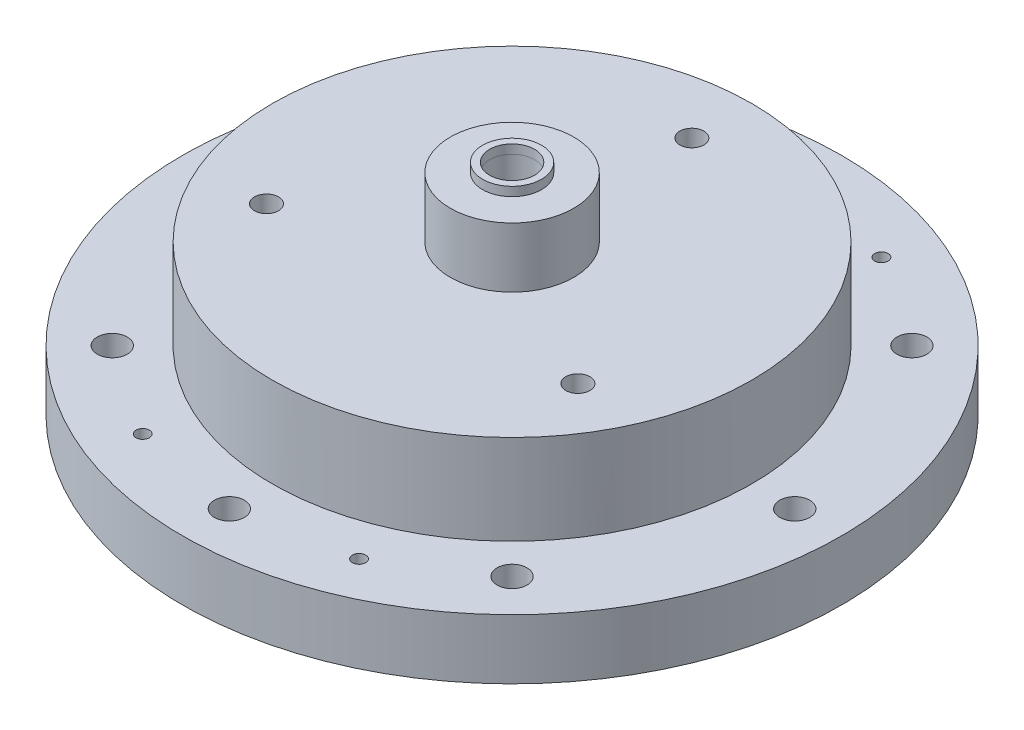
from build123d import *

# Parameters (mm, degrees)
SKETCH1_R                        = 50.8
BOSS_EXTRUDE1_DEPTH              = 25.4
SKETCH2_R                        = 69.85
SKETCH2_R_2                      = 50.8
BOSS_EXTRUDE2_DEPTH              = 12.7
CUT_EXTRUDE2_REACH               = 27.4
SKETCH4_R                        = 3.175
SKETCH5_R                        = 12.827
CUT_EXTRUDE3_DEPTH               = 19.05
CUT_EXTRUDE4_REACH               = 8.35
SKETCH6_R                        = 1.5875
SKETCH34_R                       = 13.081
SKETCH34_R_2                     = 4.7625
BOSS_EXTRUDE3_DEPTH              = 19.05
SKETCH40_R                       = 50.8
BOSS_EXTRUDE5_DEPTH              = 6.35
SKETCH38_R                       = 6.2484
BOSS_EXTRUDE4_DEPTH              = 1.905
SKETCH39_R                       = 4.7625
CUT_EXTRUDE7_DEPTH               = 6.35
SKETCH41_R                       = 4.7625
CUT_EXTRUDE8_DEPTH               = 6.35
SKETCH42_R                       = 23.7871
CUT_EXTRUDE9_DEPTH               = 6.477
F_10_24_TAPPED_HOLE1_AT_2_COUNT  = 2
F_10_24_TAPPED_HOLE1_AT_2_PITCH  = 24.695704333
F_10_24_TAPPED_HOLE1_AT_3_COUNT  = 2
F_10_24_TAPPED_HOLE1_AT_3_PITCH  = 34.925
F_10_24_TAPPED_HOLE1_AT_4_COUNT  = 2
F_10_24_TAPPED_HOLE1_AT_4_PITCH  = 24.695704333
SKETCH46_R                       = 3.175
CUT_EXTRUDE10_DEPTH              = 6.35
F_1_4_20_TAPPED_HOLE1_AT_2_COUNT = 2
F_1_4_20_TAPPED_HOLE1_AT_2_PITCH = 65.991135768
F_1_4_20_TAPPED_HOLE1_AT_3_COUNT = 2
F_1_4_20_TAPPED_HOLE1_AT_3_PITCH = 65.991135768
CUT_EXTRUDE11_START              = 6.477
SKETCH49_R                       = 23.8252
CUT_EXTRUDE11_DEPTH              = 3.937
SKETCH50_R                       = 1.4097
CUT_EXTRUDE12_DEPTH              = 41.005


with BuildPart() as part:
    # Sketch1 → Boss-Extrude1 (new body)
    with BuildSketch(Plane(origin=(0, 0, 0), x_dir=(1, 0, 0), z_dir=(0, 1, 0))):
        Circle(SKETCH1_R)
    extrude(amount=BOSS_EXTRUDE1_DEPTH)

    # Sketch2 → Boss-Extrude2 (add)
    with BuildSketch(Plane.XZ):
        Circle(SKETCH2_R)
        Circle(SKETCH2_R_2, mode=Mode.SUBTRACT)
    extrude(amount=-BOSS_EXTRUDE2_DEPTH)

    # Sketch4 → Cut-Extrude2 (cut, up to next)
    with BuildSketch(Plane.XZ, mode=Mode.PRIVATE) as cut_extrude2_sk1:
        with Locations((0, -59.9186)):
            Circle(SKETCH4_R)
    cut_extrude2_tool1 = extrude(cut_extrude2_sk1.sketch, amount=-CUT_EXTRUDE2_REACH, mode=Mode.PRIVATE) & part.part
    add(cut_extrude2_tool1.solids().sort_by_distance((0, 0, -59.9186))[0], mode=Mode.SUBTRACT)
    # Sketch4 → Cut-Extrude2 (cut, up to next)
    with BuildSketch(Plane.XZ, mode=Mode.PRIVATE) as cut_extrude2_sk2:
        with Locations((-42.368848379, -42.368848379)):
            Circle(SKETCH4_R)
    cut_extrude2_tool2 = extrude(cut_extrude2_sk2.sketch, amount=-CUT_EXTRUDE2_REACH, mode=Mode.PRIVATE) & part.part
    add(cut_extrude2_tool2.solids().sort_by_distance((-42.368848, 0, -42.368848))[0], mode=Mode.SUBTRACT)
    # Sketch4 → Cut-Extrude2 (cut, up to next)
    with BuildSketch(Plane.XZ, mode=Mode.PRIVATE) as cut_extrude2_sk3:
        with Locations((-59.9186, 0)):
            Circle(SKETCH4_R)
    cut_extrude2_tool3 = extrude(cut_extrude2_sk3.sketch, amount=-CUT_EXTRUDE2_REACH, mode=Mode.PRIVATE) & part.part
    add(cut_extrude2_tool3.solids().sort_by_distance((-59.9186, 0, 0))[0], mode=Mode.SUBTRACT)
    # Sketch4 → Cut-Extrude2 (cut, up to next)
    with BuildSketch(Plane.XZ, mode=Mode.PRIVATE) as cut_extrude2_sk4:
        with Locations((-42.368848379, 42.368848379)):
            Circle(SKETCH4_R)
    cut_extrude2_tool4 = extrude(cut_extrude2_sk4.sketch, amount=-CUT_EXTRUDE2_REACH, mode=Mode.PRIVATE) & part.part
    add(cut_extrude2_tool4.solids().sort_by_distance((-42.368848, 0, 42.368848))[0], mode=Mode.SUBTRACT)
    # Sketch4 → Cut-Extrude2 (cut, up to next)
    with BuildSketch(Plane.XZ, mode=Mode.PRIVATE) as cut_extrude2_sk5:
        with Locations((0, 59.9186)):
            Circle(SKETCH4_R)
    cut_extrude2_tool5 = extrude(cut_extrude2_sk5.sketch, amount=-CUT_EXTRUDE2_REACH, mode=Mode.PRIVATE) & part.part
    add(cut_extrude2_tool5.solids().sort_by_distance((0, 0, 59.9186))[0], mode=Mode.SUBTRACT)
    # Sketch4 → Cut-Extrude2 (cut, up to next)
    with BuildSketch(Plane.XZ, mode=Mode.PRIVATE) as cut_extrude2_sk6:
        with Locations((42.368848379, 42.368848379)):
            Circle(SKETCH4_R)
    cut_extrude2_tool6 = extrude(cut_extrude2_sk6.sketch, amount=-CUT_EXTRUDE2_REACH, mode=Mode.PRIVATE) & part.part
    add(cut_extrude2_tool6.solids().sort_by_distance((42.368848, 0, 42.368848))[0], mode=Mode.SUBTRACT)
    # Sketch4 → Cut-Extrude2 (cut, up to next)
    with BuildSketch(Plane.XZ, mode=Mode.PRIVATE) as cut_extrude2_sk7:
        with Locations((59.9186, 0)):
            Circle(SKETCH4_R)
    cut_extrude2_tool7 = extrude(cut_extrude2_sk7.sketch, amount=-CUT_EXTRUDE2_REACH, mode=Mode.PRIVATE) & part.part
    add(cut_extrude2_tool7.solids().sort_by_distance((59.9186, 0, 0))[0], mode=Mode.SUBTRACT)
    # Sketch4 → Cut-Extrude2 (cut, up to next)
    with BuildSketch(Plane.XZ, mode=Mode.PRIVATE) as cut_extrude2_sk8:
        with Locations((42.368848379, -42.368848379)):
            Circle(SKETCH4_R)
    cut_extrude2_tool8 = extrude(cut_extrude2_sk8.sketch, amount=-CUT_EXTRUDE2_REACH, mode=Mode.PRIVATE) & part.part
    add(cut_extrude2_tool8.solids().sort_by_distance((42.368848, 0, -42.368848))[0], mode=Mode.SUBTRACT)

    # Sketch5 → Cut-Extrude3 (cut)
    with BuildSketch(Plane(origin=(0, 25.4, 0), x_dir=(1, 0, 0), z_dir=(0, 1, 0))):
        Circle(SKETCH5_R)
    extrude(amount=-CUT_EXTRUDE3_DEPTH, mode=Mode.SUBTRACT)

    # Sketch6 → Cut-Extrude4 (cut, up to next)
    with BuildSketch(Plane(origin=(0, 6.35, 0), x_dir=(1, 0, 0), z_dir=(0, 1, 0)), mode=Mode.PRIVATE) as cut_extrude4_sk1:
        Circle(SKETCH6_R)
    cut_extrude4_tool1 = extrude(cut_extrude4_sk1.sketch, amount=-CUT_EXTRUDE4_REACH, mode=Mode.PRIVATE) & part.part
    add(cut_extrude4_tool1.solids().sort_by_distance((0, 6.35, 0))[0], mode=Mode.SUBTRACT)

    # Sketch34 → Boss-Extrude3 (add)
    with BuildSketch(Plane(origin=(0, 25.4, 0), x_dir=(1, 0, 0), z_dir=(0, 1, 0))):
        Circle(SKETCH34_R)
        Circle(SKETCH34_R_2, mode=Mode.SUBTRACT)
    extrude(amount=BOSS_EXTRUDE3_DEPTH)

    # Sketch40 → Boss-Extrude5 (add)
    with BuildSketch(Plane(origin=(0, 25.4, 0), x_dir=(1, 0, 0), z_dir=(0, 1, 0))):
        Circle(SKETCH40_R)
    extrude(amount=BOSS_EXTRUDE5_DEPTH)

    # Sketch41 → Cut-Extrude8 (cut)
    with BuildSketch(Plane(origin=(0, 31.75, 0), x_dir=(1, 0, 0), z_dir=(0, 1, 0))):
        Circle(SKETCH41_R)
    extrude(amount=-CUT_EXTRUDE8_DEPTH, mode=Mode.SUBTRACT)

    # Sketch42 → Cut-Extrude9 (cut)
    with BuildSketch(Plane.XZ):
        Circle(SKETCH42_R)
    extrude(amount=-CUT_EXTRUDE9_DEPTH, mode=Mode.SUBTRACT)

    # Sketch45 → #10-24 Tapped Hole1 (revolve, cut)
    with BuildSketch(Plane(origin=(0, 6.477, 17.4625), x_dir=(0, 0, -1), z_dir=(1, 0, 0))):
        Polygon((0, 0), (0, 13.840824014), (1.89865, 12.7), (1.89865, 0), align=None)
    f_10_24_tapped_hole1 = revolve(axis=Axis((0, 0.127, 17.4625), (0, 1, 0)), mode=Mode.SUBTRACT)

    # #10-24 Tapped Hole1 at 2: #10-24 Tapped Hole1 ×2
    with Locations(*[Vector(0.707106781, 0, -0.707106781) * (i * F_10_24_TAPPED_HOLE1_AT_2_PITCH) for i in range(1, F_10_24_TAPPED_HOLE1_AT_2_COUNT)]):
        add(f_10_24_tapped_hole1, mode=Mode.SUBTRACT)

    # #10-24 Tapped Hole1 at 3: #10-24 Tapped Hole1 ×2
    with Locations(*[(0, 0, -i * F_10_24_TAPPED_HOLE1_AT_3_PITCH) for i in range(1, F_10_24_TAPPED_HOLE1_AT_3_COUNT)]):
        add(f_10_24_tapped_hole1, mode=Mode.SUBTRACT)

    # #10-24 Tapped Hole1 at 4: #10-24 Tapped Hole1 ×2
    with Locations(*[Vector(-0.707106781, 0, -0.707106781) * (i * F_10_24_TAPPED_HOLE1_AT_4_PITCH) for i in range(1, F_10_24_TAPPED_HOLE1_AT_4_COUNT)]):
        add(f_10_24_tapped_hole1, mode=Mode.SUBTRACT)

    # Sketch46 → Cut-Extrude10 (cut)
    with BuildSketch(Plane.XZ):
        with Locations((-22.929855511, 55.357568157)):
            Circle(SKETCH46_R)
        with Locations((22.929855511, 55.357568157)):
            Circle(SKETCH46_R)
        with Locations((-22.929855511, -55.357568157)):
            Circle(SKETCH46_R)
        with Locations((22.929855511, -55.357568157)):
            Circle(SKETCH46_R)
    extrude(amount=-CUT_EXTRUDE10_DEPTH, mode=Mode.SUBTRACT)

    # Sketch48 → 1/4-20 Tapped Hole1 (revolve, cut)
    with BuildSketch(Plane(origin=(0, 31.75, -38.1), x_dir=(0, 0, 1), z_dir=(1, 0, 0))):
        Polygon((0, 0), (0, 15.503816902), (2.5527, 13.97), (2.5527, 0), align=None)
    f_1_4_20_tapped_hole1 = revolve(axis=Axis((0, 38.1, -38.1), (0, -1, 0)), mode=Mode.SUBTRACT)

    # 1/4-20 Tapped Hole1 at 2: 1/4-20 Tapped Hole1 ×2
    with Locations(*[Vector(0.5, 0, 0.866025404) * (i * F_1_4_20_TAPPED_HOLE1_AT_2_PITCH) for i in range(1, F_1_4_20_TAPPED_HOLE1_AT_2_COUNT)]):
        add(f_1_4_20_tapped_hole1, mode=Mode.SUBTRACT)

    # 1/4-20 Tapped Hole1 at 3: 1/4-20 Tapped Hole1 ×2
    with Locations(*[Vector(-0.5, 0, 0.866025404) * (i * F_1_4_20_TAPPED_HOLE1_AT_3_PITCH) for i in range(1, F_1_4_20_TAPPED_HOLE1_AT_3_COUNT)]):
        add(f_1_4_20_tapped_hole1, mode=Mode.SUBTRACT)

    # Sketch49 → Cut-Extrude11 (cut)
    with BuildSketch(Plane.XZ.offset(-6.477).offset(CUT_EXTRUDE11_START)):
        Circle(SKETCH49_R)
    extrude(amount=-CUT_EXTRUDE11_DEPTH, mode=Mode.SUBTRACT)

    # Sketch50 → Cut-Extrude12 (cut, through all)
    with BuildSketch(Plane.XZ.offset(-6.35)):
        with Locations((-22.929855511, 55.357568157)):
            Circle(SKETCH50_R)
        with Locations((22.929855511, 55.357568157)):
            Circle(SKETCH50_R)
        with Locations((-22.929855511, -55.357568157)):
            Circle(SKETCH50_R)
        with Locations((22.929855511, -55.357568157)):
            Circle(SKETCH50_R)
    extrude(amount=-CUT_EXTRUDE12_DEPTH, mode=Mode.SUBTRACT)


with BuildPart() as body_2:
    # Sketch38 → Boss-Extrude4 (new body)
    with BuildSketch(Plane(origin=(0, 44.45, 0), x_dir=(1, 0, 0), z_dir=(0, 1, 0))):
        Circle(SKETCH38_R)
    extrude(amount=BOSS_EXTRUDE4_DEPTH)

    # Sketch39 → Cut-Extrude7 (cut)
    with BuildSketch(Plane(origin=(0, 46.355, 0), x_dir=(1, 0, 0), z_dir=(0, 1, 0))):
        Circle(SKETCH39_R)
    extrude(amount=-CUT_EXTRUDE7_DEPTH, mode=Mode.SUBTRACT)


solid = Compound([part.part, body_2.part])
